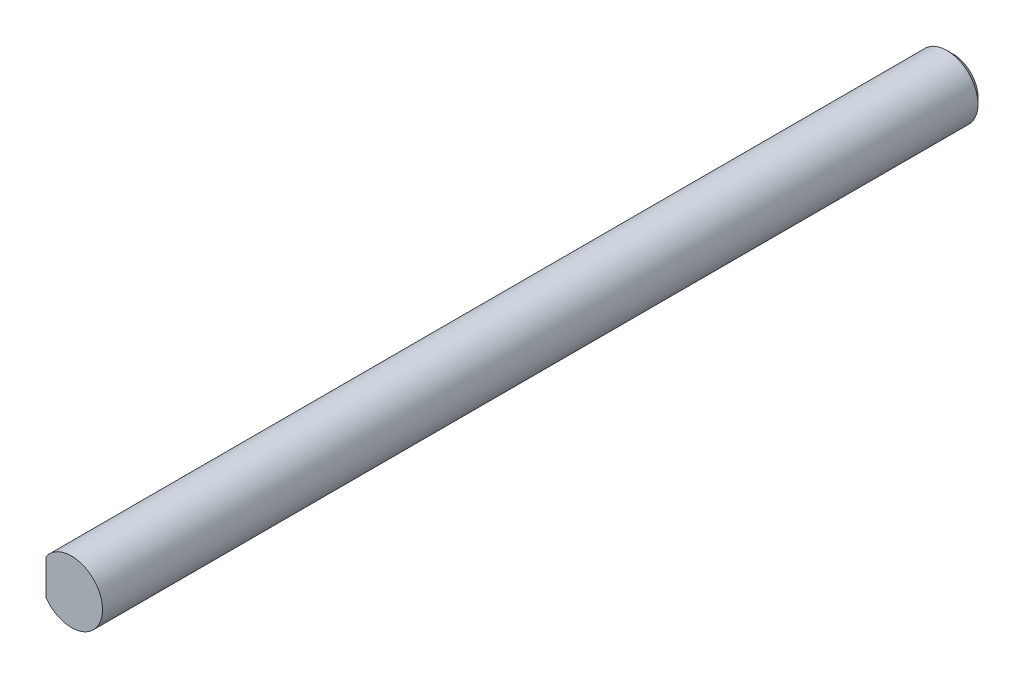
from build123d import *

# Parameters (mm, degrees)
CROQUIS1_R              = 2.5
SALIENTE_EXTRUIR1_DEPTH = 71
CUT_EXTRUDE1_DEPTH      = 14
CHAMFER1_SIZE           = 0.5


with BuildPart() as part:
    # Croquis1 → Saliente-Extruir1 (new body)
    with BuildSketch(Plane.XY):
        Circle(CROQUIS1_R)
    extrude(amount=SALIENTE_EXTRUIR1_DEPTH)

    # Sketch1 → Cut-Extrude1 (cut)
    with BuildSketch(Plane.XY.offset(71)):
        with BuildLine():
            Line((-2.05, 1.430908802), (-2.05, -1.430908802))
            ThreePointArc((-2.05, -1.430908802), (-2.5, 0), (-2.05, 1.430908802))
        make_face()
    extrude(amount=-CUT_EXTRUDE1_DEPTH, mode=Mode.SUBTRACT)

    # Chamfer1
    chamfer1_edges = [part.edges().sort_by_distance(p)[0] for p in [
        (-2.5, 0, 0),
    ]]
    chamfer(chamfer1_edges, length=CHAMFER1_SIZE)


solid = part.part
